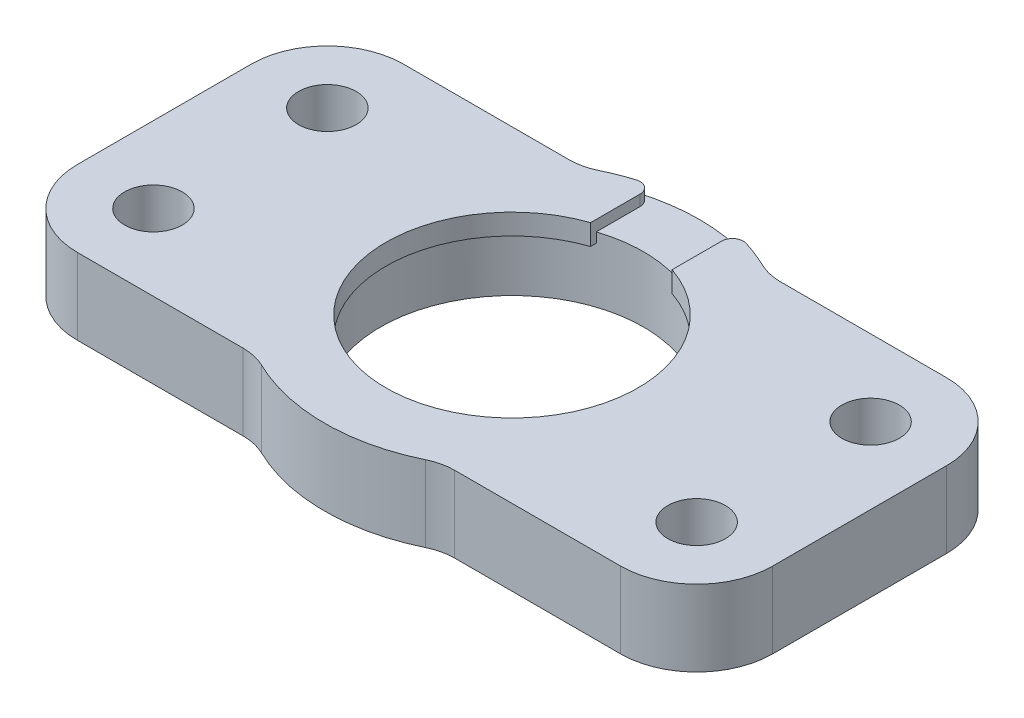
from build123d import *

# Parameters (mm, degrees)
SKETCH_2_R          = 2.65
SKETCH_2_R_2        = 12.1
EXTRUDE_1_DEPTH     = 7
SKETCH_3_R          = 12.1
SKETCH_3_R_2        = 11.6
EXTRUDE_2_DEPTH     = 1.9
FILLET_1_R          = 5
CUT_EXTRUDE_2_DEPTH = 1
CUT_EXTRUDE_3_DEPTH = 7
FILLET_3_R          = 1


with BuildPart() as part:
    # 草图2 → 凸台-拉伸1 (new body)
    with BuildSketch(Plane(origin=(0, 0, 0), x_dir=(1, 0, 0), z_dir=(0, 1, 0))):
        with BuildLine():
            Line((33.483093904, -23), (49.97, -23))
            ThreePointArc((49.97, -23), (54.919747468, -20.949747468), (56.97, -16))
            Line((56.97, -16), (56.97, 0))
            ThreePointArc((56.97, 0), (54.919747468, 4.949747468), (49.97, 7))
            Line((49.97, 7), (33.483093904, 7))
            ThreePointArc((33.483093904, 7), (24.985, 9.24), (16.486906096, 7))
            Line((16.486906096, 7), (0, 7))
            ThreePointArc((0, 7), (-4.949747468, 4.949747468), (-7, 0))
            Line((-7, 0), (-7, -16))
            ThreePointArc((-7, -16), (-4.949747468, -20.949747468), (0, -23))
            Line((0, -23), (16.486906096, -23))
            ThreePointArc((16.486906096, -23), (24.985, -25.24), (33.483093904, -23))
        make_face()
        Circle(SKETCH_2_R, mode=Mode.SUBTRACT)
        with Locations((0, -16)):
            Circle(SKETCH_2_R, mode=Mode.SUBTRACT)
        with Locations((49.97, 0)):
            Circle(SKETCH_2_R, mode=Mode.SUBTRACT)
        with Locations((49.97, -16)):
            Circle(SKETCH_2_R, mode=Mode.SUBTRACT)
        with Locations((24.985, -8)):
            Circle(SKETCH_2_R_2, mode=Mode.SUBTRACT)
    extrude(amount=EXTRUDE_1_DEPTH)

    # 草图3 → 凸台-拉伸2 (add)
    with BuildSketch(Plane(origin=(0, 7, 0), x_dir=(1, 0, 0), z_dir=(0, 1, 0))):
        with Locations((24.985, -8)):
            Circle(SKETCH_3_R)
        with Locations((24.985, -8)):
            Circle(SKETCH_3_R_2, mode=Mode.SUBTRACT)
    extrude(amount=-EXTRUDE_2_DEPTH)

    # 圆角1
    fillet_1_edges = [part.edges().sort_by_distance(p)[0] for p in [
        (16.486906096, 3.5, 23),
        (16.486906096, 3.5, -7),
        (33.483093904, 3.5, -7),
        (33.483093904, 3.5, 23),
    ]]
    fillet(fillet_1_edges, radius=FILLET_1_R)

    # 草图5 → 切除-拉伸2 (cut)
    with BuildSketch(Plane(origin=(0, 7, 0), x_dir=(1, 0, 0), z_dir=(0, 1, 0))):
        with BuildLine():
            Line((21.235, 8.827213079), (21.235, 2.977135328))
            ThreePointArc((21.235, 2.977135328), (24.985, 3.6), (28.735, 2.977135328))
            Line((28.735, 2.977135328), (28.735, 8.827213079))
            ThreePointArc((28.735, 8.827213079), (24.985, 9.24), (21.235, 8.827213079))
        make_face()
    extrude(amount=-CUT_EXTRUDE_2_DEPTH, mode=Mode.SUBTRACT)

    # 草图6 → 切除-拉伸3 (cut, through all)
    with BuildSketch(Plane(origin=(0, 6, 0), x_dir=(1, 0, 0), z_dir=(0, 1, 0))):
        with BuildLine():
            Line((28.735, 2.977135328), (28.735, 3.504238349))
            ThreePointArc((28.735, 3.504238349), (24.985, 4.1), (21.235, 3.504238349))
            Line((21.235, 3.504238349), (21.235, 2.977135328))
            ThreePointArc((21.235, 2.977135328), (24.985, 3.6), (28.735, 2.977135328))
        make_face()
    extrude(amount=-CUT_EXTRUDE_3_DEPTH, mode=Mode.SUBTRACT)

    # 圆角3
    fillet_3_edges = [part.edges().sort_by_distance(p)[0] for p in [
        (21.235, 6.5, -8.827213079),
        (28.735, 6.5, -8.827213079),
    ]]
    fillet(fillet_3_edges, radius=FILLET_3_R)


solid = part.part
